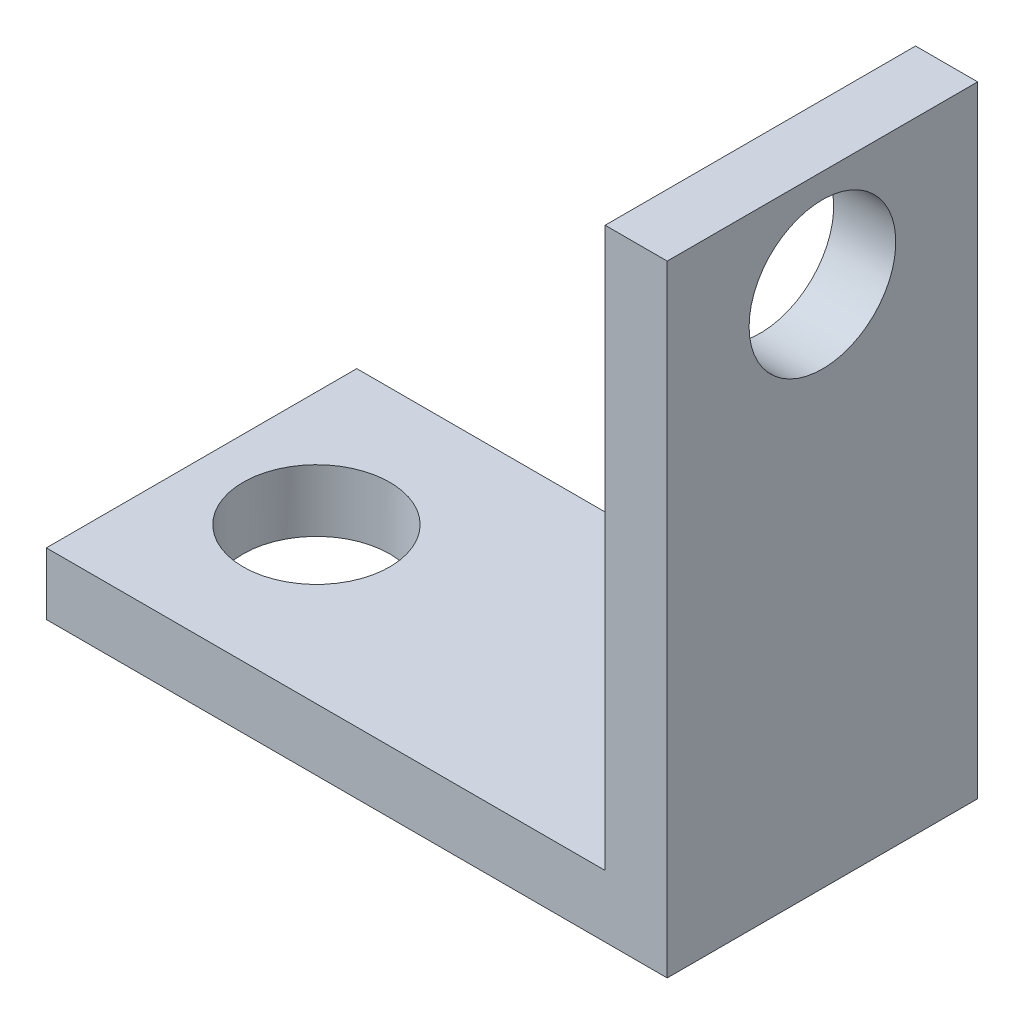
from build123d import *

# Parameters (mm, degrees)
SKETCH1_W           = 25.4
SKETCH1_H           = 12.7
BOSS_EXTRUDE1_DEPTH = 2.54
SKETCH2_W           = 2.54
SKETCH2_H           = 12.7
BOSS_EXTRUDE2_DEPTH = 22.86
SKETCH3_R           = 3
CUT_EXTRUDE1_DEPTH  = 22.86
SKETCH4_R           = 3
CUT_EXTRUDE2_DEPTH  = 22.86


with BuildPart() as part:
    # Sketch1 → Boss-Extrude1 (new body)
    with BuildSketch(Plane(origin=(0, 0, 0), x_dir=(1, 0, 0), z_dir=(0, 1, 0))):
        Rectangle(SKETCH1_W, SKETCH1_H)
    extrude(amount=BOSS_EXTRUDE1_DEPTH)

    # Sketch2 → Boss-Extrude2 (add)
    with BuildSketch(Plane(origin=(0, 2.54, 0), x_dir=(1, 0, 0), z_dir=(0, 1, 0))):
        with Locations((11.43, 0)):
            Rectangle(SKETCH2_W, SKETCH2_H)
    extrude(amount=BOSS_EXTRUDE2_DEPTH)

    # Sketch3 → Cut-Extrude1 (cut)
    with BuildSketch(Plane(origin=(0, 2.54, 0), x_dir=(1, 0, 0), z_dir=(0, 1, 0))):
        with Locations((-8, 0)):
            Circle(SKETCH3_R)
    extrude(amount=-CUT_EXTRUDE1_DEPTH, mode=Mode.SUBTRACT)

    # Sketch4 → Cut-Extrude2 (cut)
    with BuildSketch(Plane.ZY.offset(-10.16)):
        with Locations((0, 21.4)):
            Circle(SKETCH4_R)
    extrude(amount=-CUT_EXTRUDE2_DEPTH, mode=Mode.SUBTRACT)


solid = part.part
